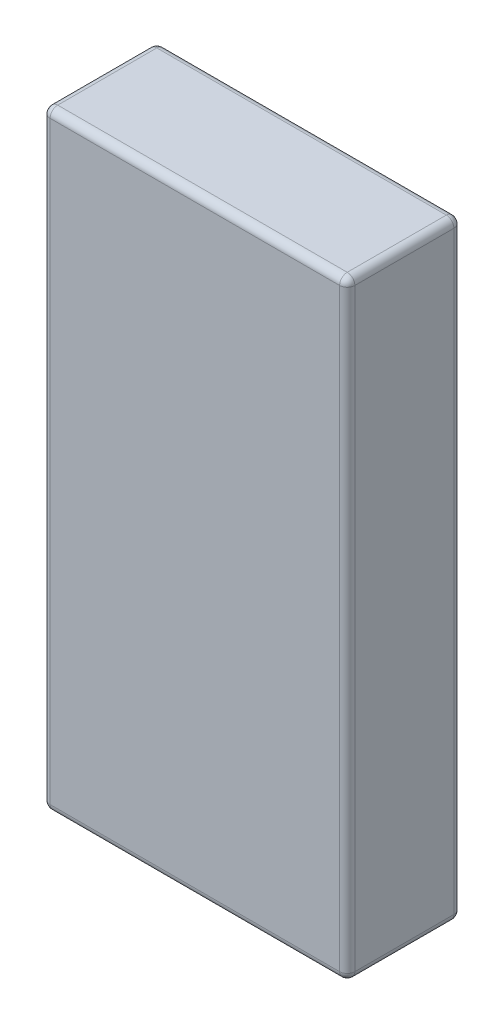
from build123d import *

# Parameters (mm, degrees)
SKETCH1_W           = 4
SKETCH1_H           = 8
BOSS_EXTRUDE1_DEPTH = 1.5
FILLET1_R           = 0.1


with BuildPart() as part:
    # Sketch1 → Boss-Extrude1 (new body)
    with BuildSketch(Plane.XY):
        Rectangle(SKETCH1_W, SKETCH1_H)
    extrude(amount=BOSS_EXTRUDE1_DEPTH)

    # Fillet1
    fillet1_edges = [part.edges().sort_by_distance(p)[0] for p in [
        (-2, 0, 1.5),
        (0, -4, 1.5),
        (2, 0, 1.5),
        (0, -4, 0),
        (-2, 0, 0),
        (0, 4, 0),
        (2, 0, 0),
        (0, 4, 1.5),
        (2, -4, 0.75),
        (-2, -4, 0.75),
        (-2, 4, 0.75),
        (2, 4, 0.75),
    ]]
    fillet(fillet1_edges, radius=FILLET1_R)


solid = part.part
